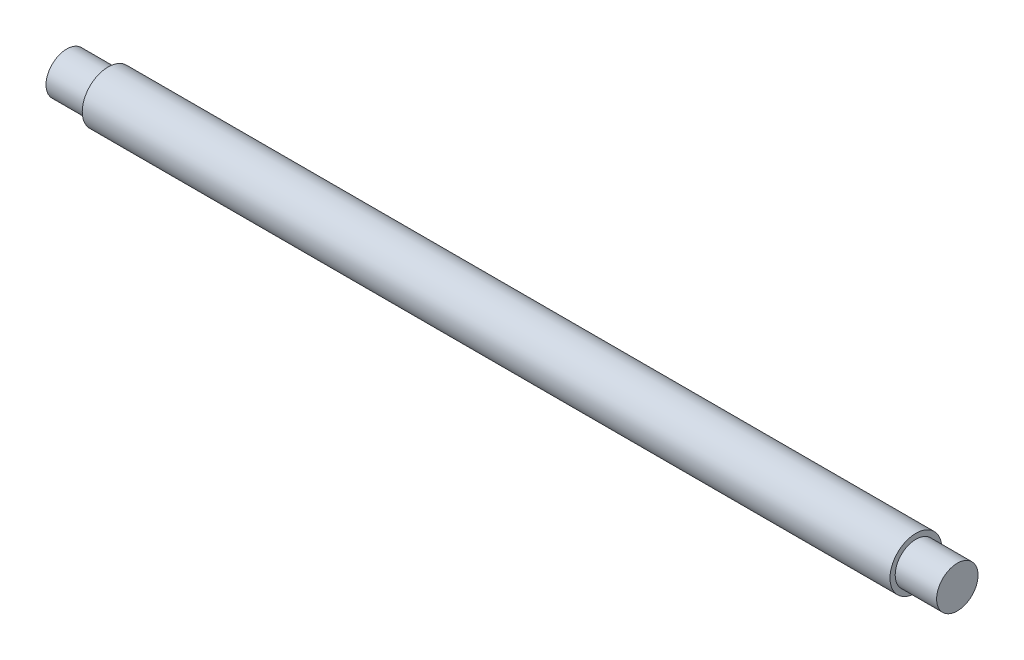
from build123d import *


with BuildPart() as part:
    # Sketch1 → Revolve1 (revolve)
    with BuildSketch(Plane.XY):
        Polygon((0, 0), (0, 4), (8, 4), (8, 5), (164, 5), (164, 4), (172, 4), (172, 0), align=None)
    revolve(axis=Axis((0, 0, 0), (1, 0, 0)))


solid = part.part
